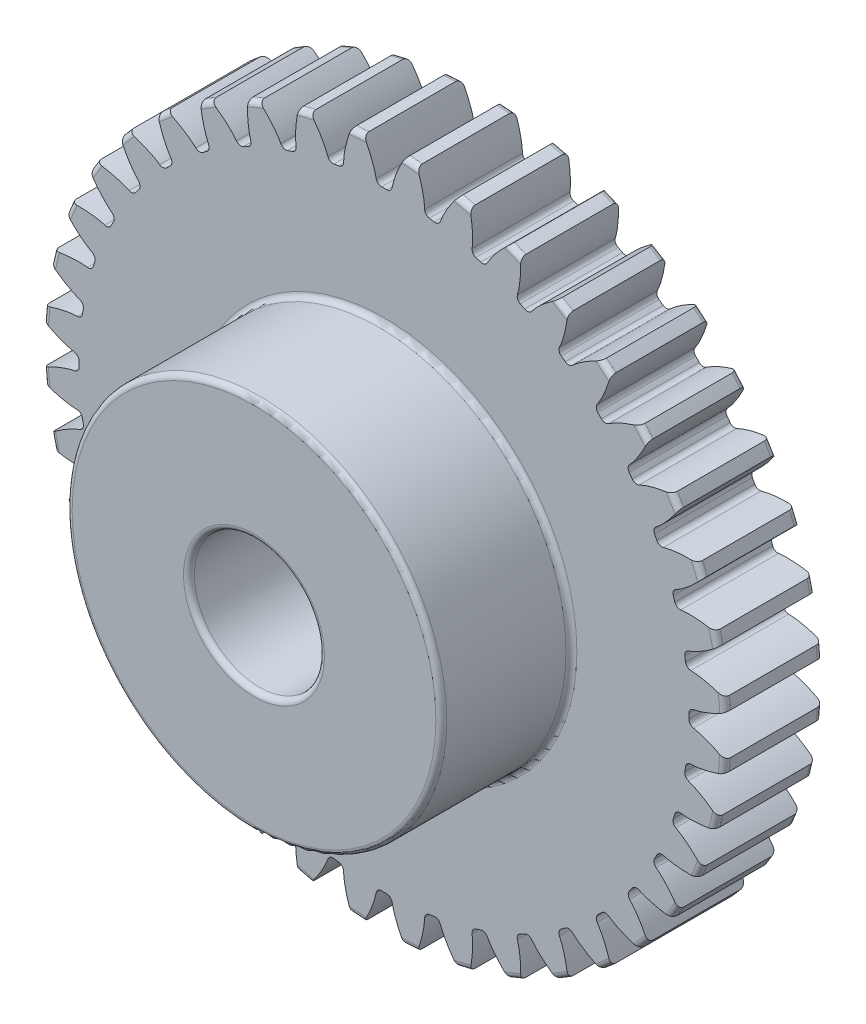
from build123d import *

# Parameters (mm, degrees)
SKETCH3_R                = 16.66875
BOSS_EXTRUDE1_DEPTH      = 5.5626
BOSS_EXTRUDE1_DEPTH_BACK = 5.5626
SKETCH5_W                = 6.35
SKETCH5_H                = 7.52475
SKETCH5_W_2              = 11.1252
SKETCH5_H_2              = 3.175
FILLET2_R                = 0.266307122
CUT_EXTRUDE1_START       = -6.5626001
CUT_EXTRUDE1_DEPTH       = 13.1252001
FILLET1_R                = 0.266307122
CIRPATTERN1_COUNT        = 40
FILLET1_OF_CIRPATTERN1_R = 0.266307122


with BuildPart() as part:
    # Sketch3 → Boss-Extrude1 (new body, two sides)
    with BuildSketch(Plane.XY) as boss_extrude1_sk:
        Circle(SKETCH3_R)
    extrude(amount=BOSS_EXTRUDE1_DEPTH)
    extrude(boss_extrude1_sk.sketch, amount=-BOSS_EXTRUDE1_DEPTH_BACK)

    # Sketch5 → Cut-Revolve1 (revolve, cut)
    with BuildSketch(Plane(origin=(0, 0, 0), x_dir=(0, 0, -1), z_dir=(1, 0, 0))):
        with Locations((-2.3876, 12.906375)):
            Rectangle(SKETCH5_W, SKETCH5_H)
        with Locations((0, 1.5875)):
            Rectangle(SKETCH5_W_2, SKETCH5_H_2)
    revolve(axis=Axis((0, 0, 5.5626), (0, 0, -1)), mode=Mode.SUBTRACT)

    # Fillet2
    fillet2_edges = [part.edges().sort_by_distance(p)[0] for p in [
        (0, -3.175, 5.5626),
        (0, -3.175, -5.5626),
        (0, -9.144, 5.5626),
        (0, -9.144, -0.7874),
        (-16.66875, 0, -0.7874),
        (-16.66875, 0, -5.5626),
    ]]
    fillet(fillet2_edges, radius=FILLET2_R)

    # Sketch4 → Cut-Extrude1 (cut)
    with BuildSketch(Plane.XY.offset(CUT_EXTRUDE1_START)):
        with BuildLine():
            Line((14.878394914, 0.36259165), (14.913192437, 0.363439678))
            add(Edge.make_bspline(
                [(14.913192437, 0.363439678), (14.915932121, 0.363535365), (14.923613754, 0.363893266), (14.938125953, 0.364923437), (14.961789134, 0.367106592), (14.9919122, 0.370626534), (15.030810507, 0.376023905), (15.076581712, 0.383472603), (15.12682317, 0.392801052), (15.181412661, 0.404183189), (15.235805402, 0.416628993), (15.28999624, 0.43005936), (15.343913358, 0.444353581), (15.409141175, 0.462750391), (15.487236161, 0.486313697), (15.578328649, 0.51604657), (15.681407364, 0.552353468), (15.786194232, 0.592121026), (15.889077748, 0.633523786), (15.992749608, 0.677967317), (16.09285943, 0.722818906), (16.196538779, 0.772080887), (16.292085972, 0.818912247), (16.398778373, 0.874340048), (16.484777514, 0.919934703), (16.573306231, 0.969501611), (16.616347812, 0.993990285), (16.638325167, 1.006658928)],
                knots=[0, 0, 0, 0, 0, 0.005376749, 0.015083688, 0.02853182, 0.04661014, 0.064854849, 0.092110526, 0.119476176, 0.146842496, 0.174208854, 0.201574956, 0.228941013, 0.256307345, 0.307035032, 0.361767352, 0.416499661, 0.471231937, 0.525964282, 0.580696616, 0.635428982, 0.690161387, 0.744893688, 0.799626082, 0.854358407, 0.909090914, 0.909090914, 0.909090914, 0.909090914, 0.909090914], degree=4))
            ThreePointArc((16.638325167, 1.006658928), (16.66875, 0), (16.638325167, -1.006658928))
            add(Edge.make_bspline(
                [(14.913192437, -0.363439678), (14.915932121, -0.363535365), (14.923613754, -0.363893266), (14.938125953, -0.364923437), (14.961789134, -0.367106592), (14.9919122, -0.370626534), (15.030810507, -0.376023905), (15.076581712, -0.383472603), (15.12682317, -0.392801052), (15.181412661, -0.404183189), (15.235805402, -0.416628993), (15.28999624, -0.43005936), (15.343913358, -0.444353581), (15.409141175, -0.462750391), (15.487236161, -0.486313697), (15.578328649, -0.51604657), (15.681407364, -0.552353468), (15.786194232, -0.592121026), (15.889077748, -0.633523786), (15.992749608, -0.677967317), (16.09285943, -0.722818906), (16.196538779, -0.772080887), (16.292085972, -0.818912247), (16.398778373, -0.874340048), (16.484777514, -0.919934703), (16.573306231, -0.969501611), (16.616347812, -0.993990285), (16.638325167, -1.006658928)],
                knots=[0, 0, 0, 0, 0, 0.005376749, 0.015083688, 0.02853182, 0.04661014, 0.064854849, 0.092110526, 0.119476176, 0.146842496, 0.174208854, 0.201574956, 0.228941013, 0.256307345, 0.307035032, 0.361767352, 0.416499661, 0.471231937, 0.525964282, 0.580696616, 0.635428982, 0.690161387, 0.744893688, 0.799626082, 0.854358407, 0.909090914, 0.909090914, 0.909090914, 0.909090914, 0.909090914], degree=4))
            Line((14.913192437, -0.363439678), (14.878394914, -0.36259165))
            ThreePointArc((14.878394914, -0.36259165), (14.8828125, 0), (14.878394914, 0.36259165))
        make_face()
    cut_extrude1 = extrude(amount=CUT_EXTRUDE1_DEPTH, mode=Mode.SUBTRACT)

    # Fillet1
    fillet1_edges = [part.edges().sort_by_distance(p)[0] for p in [
        (14.878394914, -0.36259165, -3.175),
        (14.878394914, 0.36259165, -3.175),
    ]]
    fillet(fillet1_edges, radius=FILLET1_R)

    # CirPattern1: Cut-Extrude1 ×40 about axis
    cirpattern1_axis = Axis((0, 0, 5.5626), (0, 0, -1))
    for i in range(1, CIRPATTERN1_COUNT):
        add(cut_extrude1.rotate(cirpattern1_axis, i * 360 / CIRPATTERN1_COUNT), mode=Mode.SUBTRACT)

    # Fillet1 of CirPattern1
    fillet1_of_cirpattern1_edges = [part.edges().sort_by_distance(p)[0] for p in [
        (14.638495352, -2.685621294, -3.175),
        (14.751939014, -1.969366204, -3.175),
        (14.038147453, -4.942522029, -3.175),
        (14.262241416, -4.252831726, -3.175),
        (13.092133773, -7.077721468, -3.175),
        (13.421360102, -6.431578416, -3.175),
        (11.82374831, -9.038643915, -3.175),
        (12.250000359, -8.451958301, -3.175),
        (10.264222922, -10.777004951, -3.175),
        (10.777004951, -10.264222922, -3.175),
        (8.451958301, -12.250000359, -3.175),
        (9.038643915, -11.82374831, -3.175),
        (6.431578416, -13.421360102, -3.175),
        (7.077721468, -13.092133773, -3.175),
        (4.252831726, -14.262241416, -3.175),
        (4.942522029, -14.038147453, -3.175),
        (1.969366204, -14.751939014, -3.175),
        (2.685621294, -14.638495352, -3.175),
        (-0.36259165, -14.878394914, -3.175),
        (0.36259165, -14.878394914, -3.175),
        (-2.685621294, -14.638495352, -3.175),
        (-1.969366204, -14.751939014, -3.175),
        (-4.942522029, -14.038147453, -3.175),
        (-4.252831726, -14.262241416, -3.175),
        (-7.077721468, -13.092133773, -3.175),
        (-6.431578416, -13.421360102, -3.175),
        (-9.038643915, -11.82374831, -3.175),
        (-8.451958301, -12.250000359, -3.175),
        (-10.777004951, -10.264222922, -3.175),
        (-10.264222922, -10.777004951, -3.175),
        (-12.250000359, -8.451958301, -3.175),
        (-11.82374831, -9.038643915, -3.175),
        (-13.421360102, -6.431578416, -3.175),
        (-13.092133773, -7.077721468, -3.175),
        (-14.262241416, -4.252831726, -3.175),
        (-14.038147453, -4.942522029, -3.175),
        (-14.751939014, -1.969366204, -3.175),
        (-14.638495352, -2.685621294, -3.175),
        (-14.878394914, 0.36259165, -3.175),
        (-14.878394914, -0.36259165, -3.175),
        (-14.638495352, 2.685621294, -3.175),
        (-14.751939014, 1.969366204, -3.175),
        (-14.038147453, 4.942522029, -3.175),
        (-14.262241416, 4.252831726, -3.175),
        (-13.092133773, 7.077721468, -3.175),
        (-13.421360102, 6.431578416, -3.175),
        (-11.82374831, 9.038643915, -3.175),
        (-12.250000359, 8.451958301, -3.175),
        (-10.264222922, 10.777004951, -3.175),
        (-10.777004951, 10.264222922, -3.175),
        (-8.451958301, 12.250000359, -3.175),
        (-9.038643915, 11.82374831, -3.175),
        (-6.431578416, 13.421360102, -3.175),
        (-7.077721468, 13.092133773, -3.175),
        (-4.252831726, 14.262241416, -3.175),
        (-4.942522029, 14.038147453, -3.175),
        (-1.969366204, 14.751939014, -3.175),
        (-2.685621294, 14.638495352, -3.175),
        (0.36259165, 14.878394914, -3.175),
        (-0.36259165, 14.878394914, -3.175),
        (2.685621294, 14.638495352, -3.175),
        (1.969366204, 14.751939014, -3.175),
        (4.942522029, 14.038147453, -3.175),
        (4.252831726, 14.262241416, -3.175),
        (7.077721468, 13.092133773, -3.175),
        (6.431578416, 13.421360102, -3.175),
        (9.038643915, 11.82374831, -3.175),
        (8.451958301, 12.250000359, -3.175),
        (10.777004951, 10.264222922, -3.175),
        (10.264222922, 10.777004951, -3.175),
        (12.250000359, 8.451958301, -3.175),
        (11.82374831, 9.038643915, -3.175),
        (13.421360102, 6.431578416, -3.175),
        (13.092133773, 7.077721468, -3.175),
        (14.262241416, 4.252831726, -3.175),
        (14.038147453, 4.942522029, -3.175),
        (14.751939014, 1.969366204, -3.175),
        (14.638495352, 2.685621294, -3.175),
    ]]
    fillet(fillet1_of_cirpattern1_edges, radius=FILLET1_OF_CIRPATTERN1_R)


solid = part.part
